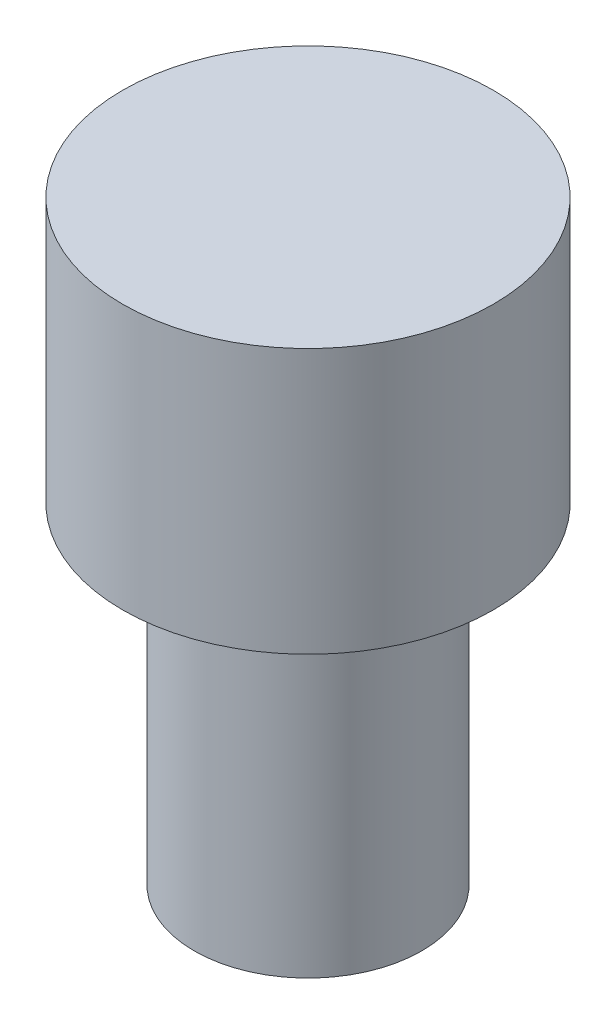
from build123d import *


with BuildPart() as part:
    # Sketch1 → Revolve1 (revolve)
    with BuildSketch(Plane(origin=(0, 0, 0), x_dir=(0, 0, -1), z_dir=(1, 0, 0))):
        Polygon((0, 2.54), (0, -3.175), (1.0922, -3.175), (1.0922, 0), (1.778, 0), (1.778, 2.54), align=None)
    revolve(axis=Axis((0, -20.451032784, 0), (0, 1, 0)))


solid = part.part
